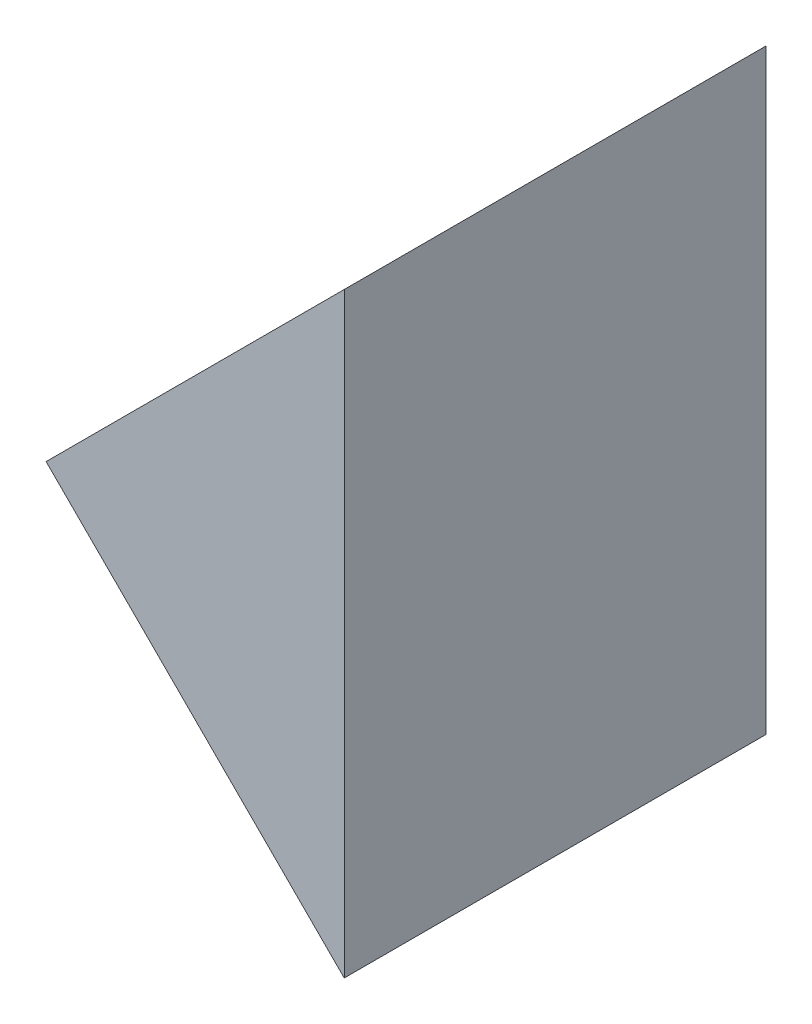
from build123d import *

# Parameters (mm, degrees)
EXTRUDE_1_DEPTH = 5


with BuildPart() as part:
    # 草图1 → 凸台-拉伸1 (new body)
    with BuildSketch(Plane.XY):
        Polygon((55.476669953, 13.775692553), (59.012203859, 17.311226459), (59.012203859, 10.240158647), align=None)
    extrude(amount=EXTRUDE_1_DEPTH)


solid = part.part
